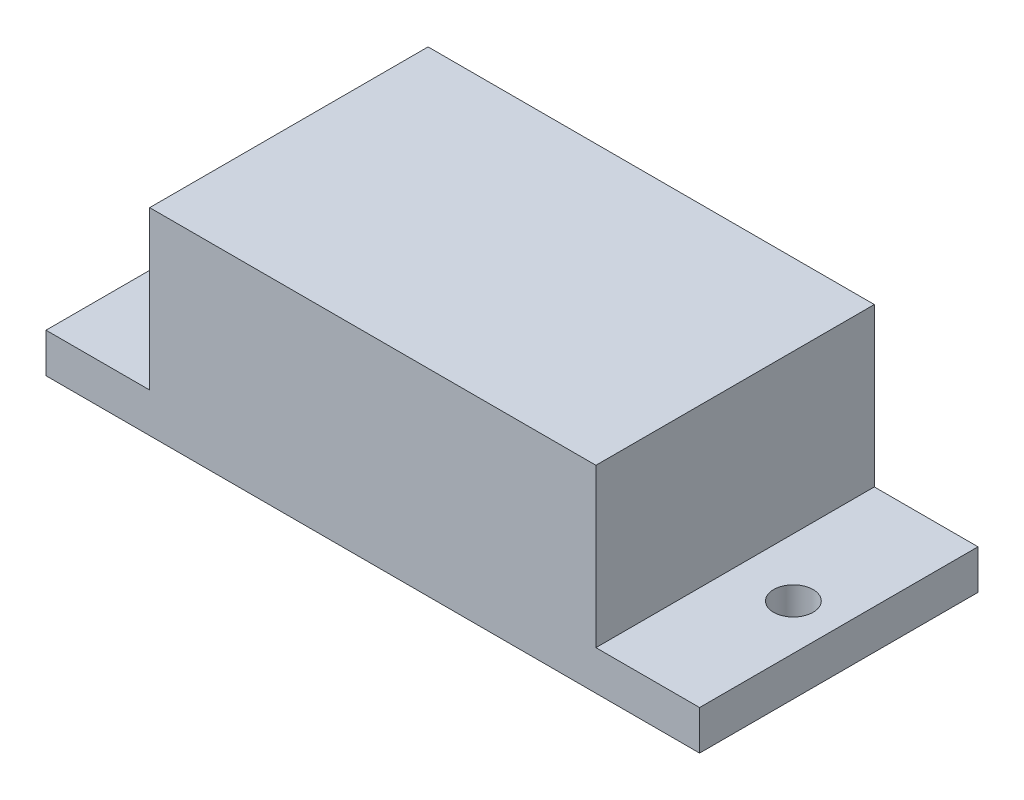
from build123d import *

# Parameters (mm, degrees)
SKETCH1_W                    = 22.6
SKETCH1_H                    = 14.1
BOSS_EXTRUDE1_DEPTH          = 8
SKETCH2_W                    = 33.1
SKETCH2_H                    = 14.1
BOSS_EXTRUDE2_DEPTH          = 2
F_2_0_2_DIAMETER_HOLE1_D     = 2
F_2_0_2_DIAMETER_HOLE1_DEPTH = 2


with BuildPart() as part:
    # Sketch1 → Boss-Extrude1 (new body)
    with BuildSketch(Plane(origin=(0, 0, 0), x_dir=(1, 0, 0), z_dir=(0, 1, 0))):
        Rectangle(SKETCH1_W, SKETCH1_H)
    extrude(amount=BOSS_EXTRUDE1_DEPTH)

    # Sketch2 → Boss-Extrude2 (add)
    with BuildSketch(Plane.XZ):
        Rectangle(SKETCH2_W, SKETCH2_H)
    extrude(amount=BOSS_EXTRUDE2_DEPTH)

    # Ø2.0 (2) Diameter Hole1
    with Locations(Plane(origin=(0, 0, 0), x_dir=(1, 0, 0), z_dir=(0, 1, 0))):
        with Locations((-14.25, 0), (14.25, 0)):
            Hole(F_2_0_2_DIAMETER_HOLE1_D / 2, depth=F_2_0_2_DIAMETER_HOLE1_DEPTH)


solid = part.part
